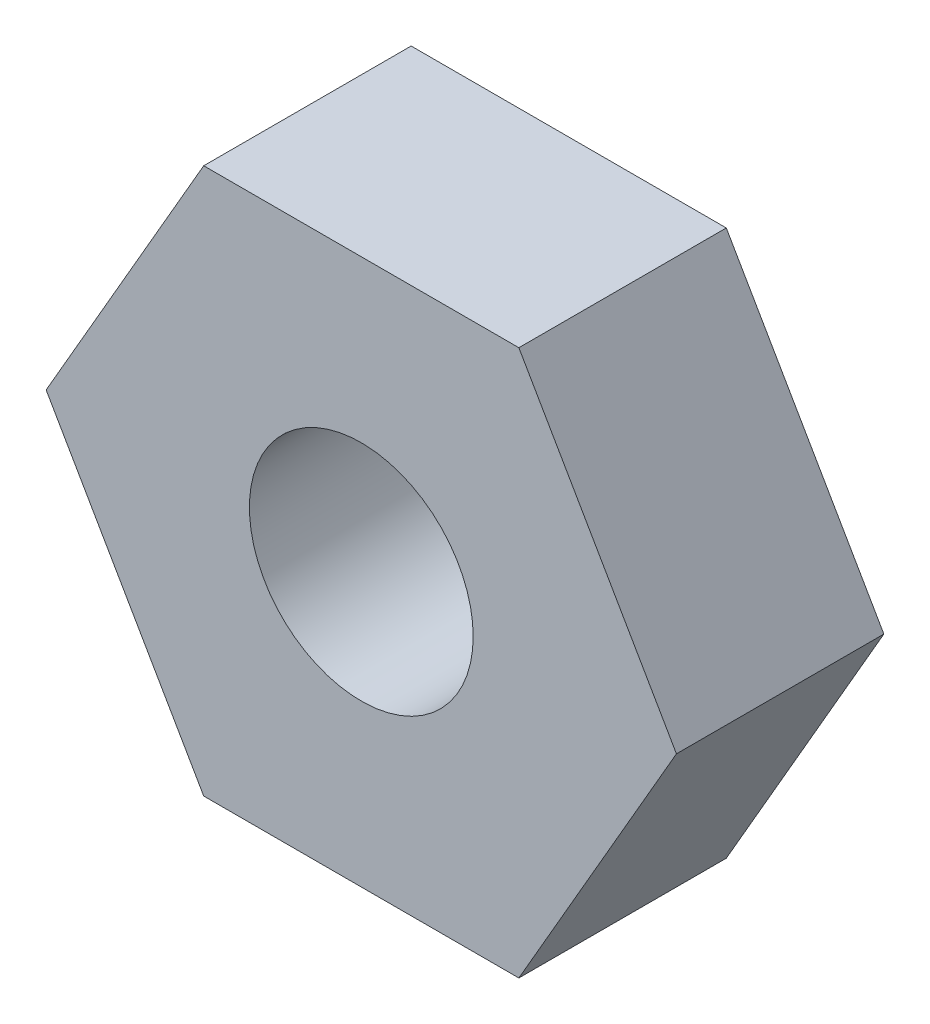
from build123d import *

# Parameters (mm, degrees)
EXTRUDE_1_DEPTH      = 1.9
HOLE_WIZARD_M2_5_1_D = 2.05


with BuildPart() as part:
    # 草图1 → 凸台-拉伸1 (new body)
    with BuildSketch(Plane.XY):
        Polygon((-2.886751346, 0), (-1.443375673, -2.5), (1.443375673, -2.5), (2.886751346, 0), (1.443375673, 2.5), (-1.443375673, 2.5), align=None)
    extrude(amount=EXTRUDE_1_DEPTH)

    # M2.5 螺纹孔1 (through all)
    with Locations(Plane.XY.offset(1.9)):
        with Locations((0, 0)):
            Hole(HOLE_WIZARD_M2_5_1_D / 2)


solid = part.part
